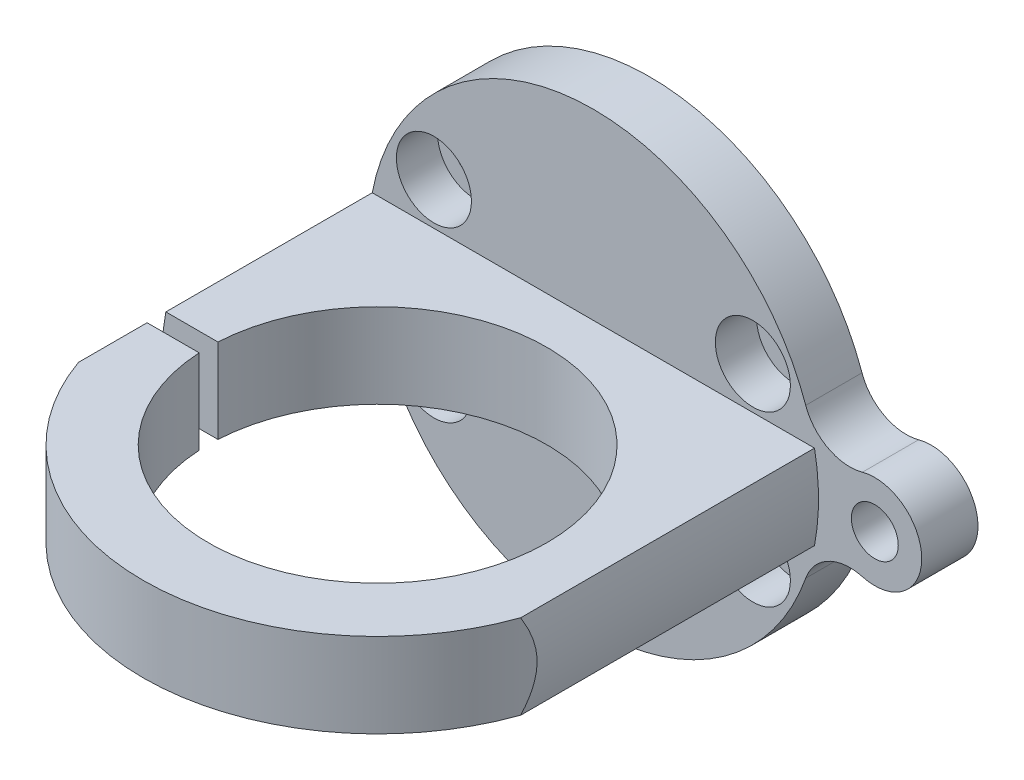
from build123d import *

# Parameters (mm, degrees)
SKETCH1_R                                          = 24
BOSS_EXTRUDE1_DEPTH                                = 6
BOSS_EXTRUDE2_DEPTH                                = 4.5
BOSS_EXTRUDE2_DEPTH_BACK                           = 4.5
CHAMBRAGE_POUR_VIS_T_TE_HEXAGONALE_M42_D           = 4.5
CHAMBRAGE_POUR_VIS_T_TE_HEXAGONALE_M42_CBORE_D     = 8
CHAMBRAGE_POUR_VIS_T_TE_HEXAGONALE_M42_CBORE_DEPTH = 4.4
CHAMBRAGE_POUR_VIS_T_TE_HEXAGONALE_M31_D           = 3.4
CHAMBRAGE_POUR_VIS_T_TE_HEXAGONALE_M31_DEPTH       = 21
CHAMBRAGE_POUR_VIS_T_TE_HEXAGONALE_M31_CBORE_D     = 6.5
CHAMBRAGE_POUR_VIS_T_TE_HEXAGONALE_M31_CBORE_DEPTH = 15.4
TROU_POUR_TARAUDAGE_POUR_TROU_TARAUD_M3_D          = 2.5
TROU_POUR_TARAUDAGE_POUR_TROU_TARAUD_M3_DEPTH      = 10
TROU_POUR_TARAUDAGE_POUR_TROU_TARAUD_M3_TIP        = 0.751075774
ENL_V_MAT_EXTRU_3_DEPTH                            = 60.203040586
ENL_V_MAT_EXTRU_3_DEPTH_BACK                       = 60.203040586
ESQUISSE8_OUTSIDE_W                                = 69.572
ESQUISSE8_OUTSIDE_H                                = 67.572
ESQUISSE8_OUTSIDE_R                                = 24
BOSS_EXTRU_1_DEPTH                                 = 6
TROU_POUR_TARAUDAGE_POUR_TROU_TARAUD_M6_D          = 5


with BuildPart() as part:
    # Sketch1 → Boss-Extrude1 (new body)
    with BuildSketch(Plane.XY):
        Circle(SKETCH1_R)
    extrude(amount=-BOSS_EXTRUDE1_DEPTH)

    # Sketch2 → Boss-Extrude2 (add, two sides: drawn at the far end of the back side and taken through both)
    with BuildSketch(Plane(origin=(0, 0, 0), x_dir=(1, 0, 0), z_dir=(0, 1, 0)).offset(-BOSS_EXTRUDE2_DEPTH_BACK)):
        with BuildLine():
            Line((-18.02227788, -24), (-24.979991994, -24))
            ThreePointArc((-24.979991994, -24), (0.50010007, -47.994997498), (25, -23))
            Line((25, -23), (25, 6))
            Line((25, 6), (-25, 6))
            Line((-25, 6), (-25, -22))
            Line((-25, -22), (-18.02227788, -22))
            ThreePointArc((-18.02227788, -22), (0.500192092, -4.956931861), (18.05, -23))
            ThreePointArc((18.05, -23), (0.500192092, -41.043068139), (-18.02227788, -24))
        make_face()
    extrude(amount=BOSS_EXTRUDE2_DEPTH + BOSS_EXTRUDE2_DEPTH_BACK)

    # Chambrage pour vis à tête hexagonale M42 (through all)
    with Locations(Plane.XY):
        with Locations((17, 9), (-17, -9), (-17, 9), (17, -9)):
            CounterBoreHole(CHAMBRAGE_POUR_VIS_T_TE_HEXAGONALE_M42_D / 2, CHAMBRAGE_POUR_VIS_T_TE_HEXAGONALE_M42_CBORE_D / 2, CHAMBRAGE_POUR_VIS_T_TE_HEXAGONALE_M42_CBORE_DEPTH)

    # Chambrage pour vis à tête hexagonale M31
    with Locations(Plane(origin=(0, 0, 44), x_dir=(-1, 0, 0), z_dir=(0, 0, 1))):
        with Locations((21.5, 0)):
            CounterBoreHole(CHAMBRAGE_POUR_VIS_T_TE_HEXAGONALE_M31_D / 2, CHAMBRAGE_POUR_VIS_T_TE_HEXAGONALE_M31_CBORE_D / 2, CHAMBRAGE_POUR_VIS_T_TE_HEXAGONALE_M31_CBORE_DEPTH, depth=CHAMBRAGE_POUR_VIS_T_TE_HEXAGONALE_M31_DEPTH)

    # Trou pour taraudage pour trou taraudé M31
    with Locations(Plane.XY.offset(22)):
        with Locations((-21.5, 0)):
            Hole(TROU_POUR_TARAUDAGE_POUR_TROU_TARAUD_M3_D / 2, depth=TROU_POUR_TARAUDAGE_POUR_TROU_TARAUD_M3_DEPTH)
            with Locations((0, 0, -(TROU_POUR_TARAUDAGE_POUR_TROU_TARAUD_M3_DEPTH + TROU_POUR_TARAUDAGE_POUR_TROU_TARAUD_M3_TIP / 2))):  # 118° drill point
                Cone(0, TROU_POUR_TARAUDAGE_POUR_TROU_TARAUD_M3_D / 2, TROU_POUR_TARAUDAGE_POUR_TROU_TARAUD_M3_TIP, mode=Mode.SUBTRACT)

    # Esquisse8 outside → Enlèv. mat.-Extru.3 (cut, two sides: drawn at the far end of the back side and taken through both)
    with BuildSketch(Plane.XY.offset(-ENL_V_MAT_EXTRU_3_DEPTH_BACK)):
        Rectangle(ESQUISSE8_OUTSIDE_W, ESQUISSE8_OUTSIDE_H)
        Circle(ESQUISSE8_OUTSIDE_R, mode=Mode.SUBTRACT)
    extrude(amount=ENL_V_MAT_EXTRU_3_DEPTH + ENL_V_MAT_EXTRU_3_DEPTH_BACK, mode=Mode.SUBTRACT)

    # Esquisse9 → Boss.-Extru.1 (add)
    with BuildSketch(Plane(origin=(0, 0, -6), x_dir=(-1, 0, 0), z_dir=(0, 0, -1))):
        with BuildLine():
            ThreePointArc((-28.675, 4.82124206), (-35, 0), (-28.675, -4.82124206))
            ThreePointArc((-28.675, -4.82124206), (-25.033036693, -5.211718832), (-22.634482759, -7.979986858))
            ThreePointArc((-22.634482759, -7.979986858), (-24, 0), (-22.634482759, 7.979986858))
            ThreePointArc((-22.634482759, 7.979986858), (-25.033036693, 5.211718832), (-28.675, 4.82124206))
        make_face()
    extrude(amount=-BOSS_EXTRU_1_DEPTH)

    # Trou pour taraudage pour trou taraudé M62 (through all)
    with Locations(Plane.XY):
        with Locations((30, 0)):
            Hole(TROU_POUR_TARAUDAGE_POUR_TROU_TARAUD_M6_D / 2)


solid = part.part
